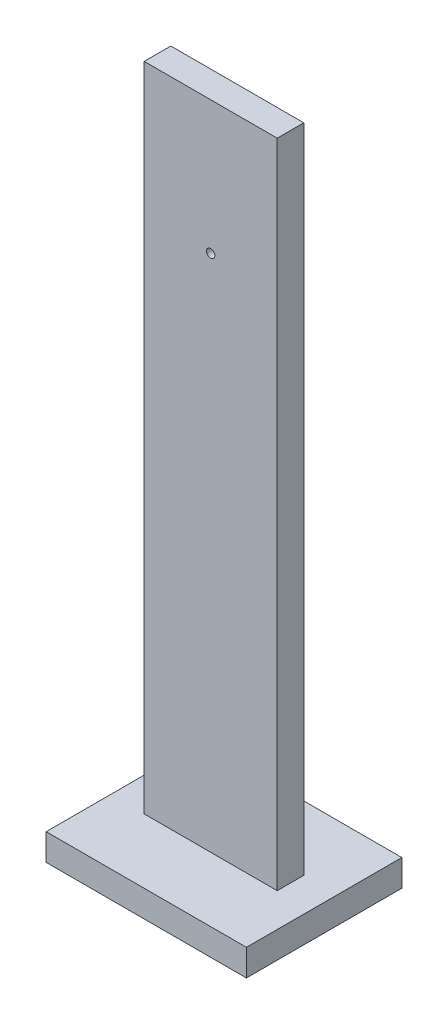
from build123d import *

# Parameters (mm, degrees)
CROQUIS1_W              = 100
CROQUIS1_H              = 500
CROQUIS1_R              = 3.125
SALIENTE_EXTRUIR1_DEPTH = 10
CROQUIS2_W              = 150.55959244
CROQUIS2_H              = 116.869560182
SALIENTE_EXTRUIR2_DEPTH = 10


with BuildPart() as part:
    # Croquis1 → Saliente-Extruir1 (new body, symmetric)
    with BuildSketch(Plane.XY):
        Rectangle(CROQUIS1_W, CROQUIS1_H)
        with Locations((0, 150)):
            Circle(CROQUIS1_R, mode=Mode.SUBTRACT)
    extrude(amount=SALIENTE_EXTRUIR1_DEPTH, both=True)

    # Croquis2 → Saliente-Extruir2 (add, symmetric)
    with BuildSketch(Plane.XZ.offset(250)):
        Rectangle(CROQUIS2_W, CROQUIS2_H)
    extrude(amount=SALIENTE_EXTRUIR2_DEPTH, both=True)


solid = part.part
